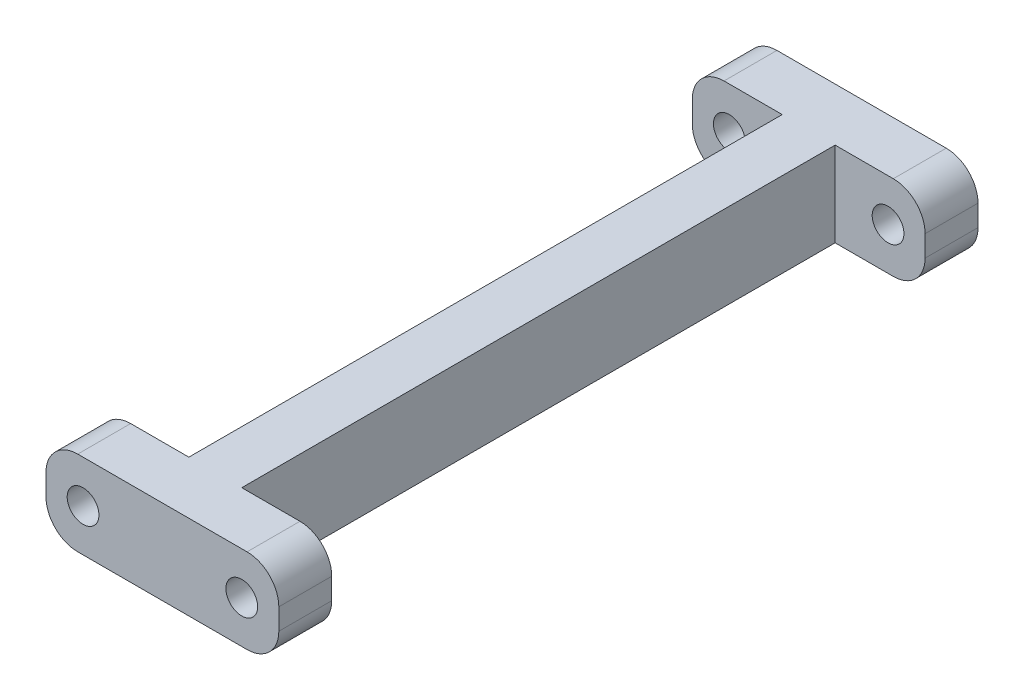
from build123d import *

# Parameters (mm, degrees)
SKETCH1_W           = 22
SKETCH1_H           = 8
SKETCH1_R           = 1.5
BOSS_EXTRUDE1_DEPTH = 5
SKETCH2_W           = 5
SKETCH2_H           = 8
BOSS_EXTRUDE2_DEPTH = 61.0706
SKETCH4_W           = 22
SKETCH4_H           = 8
SKETCH4_R           = 1.5
BOSS_EXTRUDE3_DEPTH = 5
FILLET1_R           = 3


with BuildPart() as part:
    # Sketch1 → Boss-Extrude1 (new body)
    with BuildSketch(Plane.XY):
        with Locations((11, 4)):
            Rectangle(SKETCH1_W, SKETCH1_H)
        with Locations((3.5, 4)):
            Circle(SKETCH1_R, mode=Mode.SUBTRACT)
        with Locations((18.5, 4)):
            Circle(SKETCH1_R, mode=Mode.SUBTRACT)
    extrude(amount=BOSS_EXTRUDE1_DEPTH)

    # Sketch2 → Boss-Extrude2 (add)
    with BuildSketch(Plane.XY.offset(5)):
        with Locations((11, 4)):
            Rectangle(SKETCH2_W, SKETCH2_H)
    extrude(amount=BOSS_EXTRUDE2_DEPTH)

    # Sketch4 → Boss-Extrude3 (add)
    with BuildSketch(Plane.XY.offset(66.0706)):
        with Locations((11, 4)):
            Rectangle(SKETCH4_W, SKETCH4_H)
        with Locations((3.5, 4)):
            Circle(SKETCH4_R, mode=Mode.SUBTRACT)
        with Locations((18.5, 4)):
            Circle(SKETCH4_R, mode=Mode.SUBTRACT)
    extrude(amount=-BOSS_EXTRUDE3_DEPTH)

    # Fillet1
    fillet1_edges = [part.edges().sort_by_distance(p)[0] for p in [
        (22, 0, 63.5706),
        (0, 8, 63.5706),
        (0, 0, 63.5706),
        (22, 8, 63.5706),
        (0, 8, 2.5),
        (22, 8, 2.5),
        (22, 0, 2.5),
        (0, 0, 2.5),
    ]]
    fillet(fillet1_edges, radius=FILLET1_R)


solid = part.part
